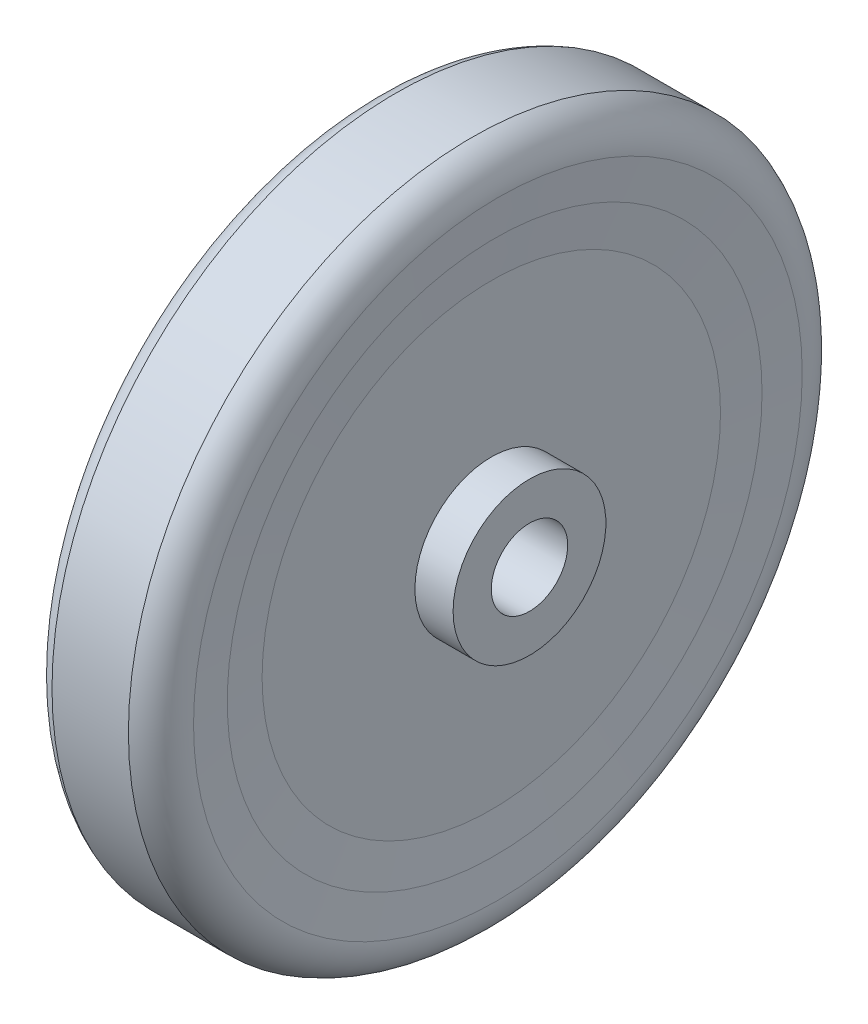
from build123d import *

# Parameters (mm, degrees)
OBERFL_CHE_LINEAR_AUSTRAGEN1_1_BACK  = 9
OBERFL_CHE_LINEAR_AUSTRAGEN1_1_DEPTH = 18
OBERFL_CHE_LINEAR_AUSTRAGEN1_2_BACK  = 9
OBERFL_CHE_LINEAR_AUSTRAGEN1_2_DEPTH = 18


with BuildPart() as part:
    # Skizze1 → Rotation1 (revolve)
    with BuildSketch(Plane.XY, mode=Mode.PRIVATE) as rotation1_sk:
        with BuildLine():
            Line((-12.5, 5), (-12.5, 10))
            Line((-12.5, 10), (-7.5, 10))
            Line((-7.5, 10), (-7.5, 30))
            Line((-7.5, 30), (-8.360375819, 39.834140612))
            ThreePointArc((-8.360375819, 39.834140612), (-7.570668397, 42.996325154), (-5, 45))
            Line((-5, 45), (5, 45))
            ThreePointArc((5, 45), (7.570668397, 42.996325154), (8.360375819, 39.834140612))
            Line((8.360375819, 39.834140612), (7.5, 30))
            Line((7.5, 30), (7.5, 10))
            Line((7.5, 10), (12.5, 10))
            Line((12.5, 10), (12.5, 5))
            Line((12.5, 5), (-12.5, 5))
        make_face()
    revolve(rotation1_sk.sketch.rotate(Axis((0, 0, 0), (1, 0, 0)), 90), axis=Axis((0, 0, 0), (1, 0, 0)))  # turned: the seam where the file's is


with BuildPart() as body_2:
    # Abspalten1: the piece behind the surface
    add(part.part)
    # Oberfläche-Linear austragen1: a surface, the sketch's curves swept straight by 18 mm
    with BuildLine(Plane(origin=(0, 0, 0), x_dir=(0, 0, -1), z_dir=(1, 0, 0)).offset(-OBERFL_CHE_LINEAR_AUSTRAGEN1_1_BACK), mode=Mode.PRIVATE) as oberfl_che_linear_austragen1_1_path:
        CenterArc((0, 0), 35, 0, 360)
    oberfl_che_linear_austragen1_1 = Shell.extrude(oberfl_che_linear_austragen1_1_path.wire(), (1 * OBERFL_CHE_LINEAR_AUSTRAGEN1_1_DEPTH, 0 * OBERFL_CHE_LINEAR_AUSTRAGEN1_1_DEPTH, 0 * OBERFL_CHE_LINEAR_AUSTRAGEN1_1_DEPTH))
    split(bisect_by=oberfl_che_linear_austragen1_1, keep=Keep.BOTTOM)


with BuildPart() as part_1:
    add(part.part)

    # Abspalten1: split by a surface, the side it looks to stays
    # Oberfläche-Linear austragen1: a surface, the sketch's curves swept straight by 18 mm
    with BuildLine(Plane(origin=(0, 0, 0), x_dir=(0, 0, -1), z_dir=(1, 0, 0)).offset(-OBERFL_CHE_LINEAR_AUSTRAGEN1_2_BACK), mode=Mode.PRIVATE) as oberfl_che_linear_austragen1_2_path:
        CenterArc((0, 0), 35, 0, 360)
    oberfl_che_linear_austragen1_2 = Shell.extrude(oberfl_che_linear_austragen1_2_path.wire(), (1 * OBERFL_CHE_LINEAR_AUSTRAGEN1_2_DEPTH, 0 * OBERFL_CHE_LINEAR_AUSTRAGEN1_2_DEPTH, 0 * OBERFL_CHE_LINEAR_AUSTRAGEN1_2_DEPTH))
    split(bisect_by=oberfl_che_linear_austragen1_2, keep=Keep.TOP)


solid = Compound([body_2.part, part_1.part])
